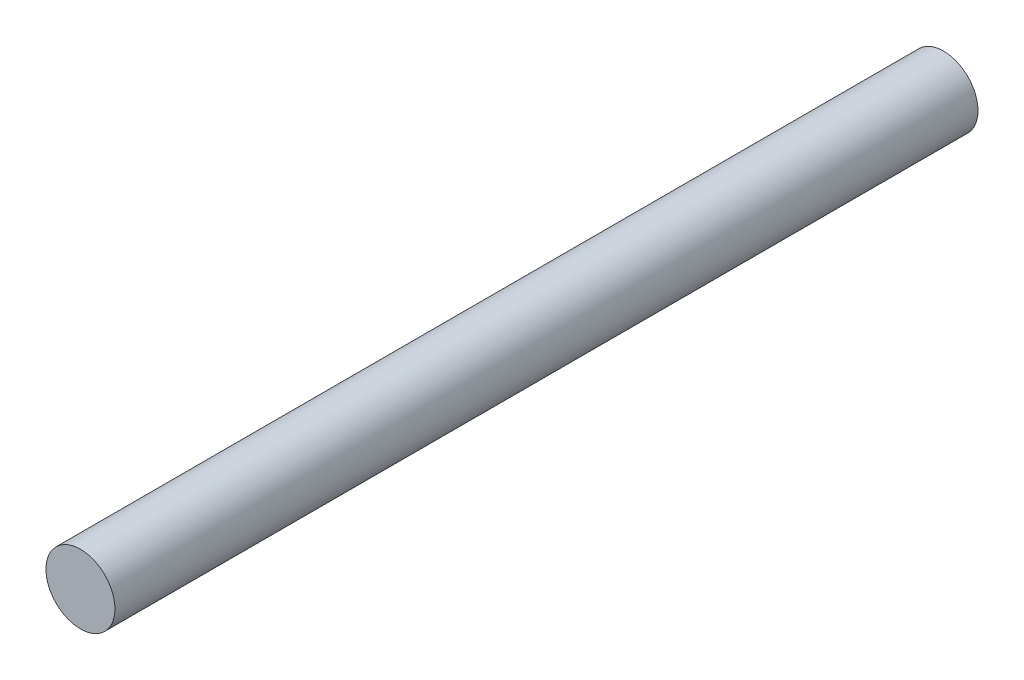
from build123d import *

# Parameters (mm, degrees)
SKETCH1_R           = 25
BOSS_EXTRUDE1_DEPTH = 625


with BuildPart() as part:
    # Sketch1 → Boss-Extrude1 (new body)
    with BuildSketch(Plane.XY):
        Circle(SKETCH1_R)
    extrude(amount=BOSS_EXTRUDE1_DEPTH)


solid = part.part
